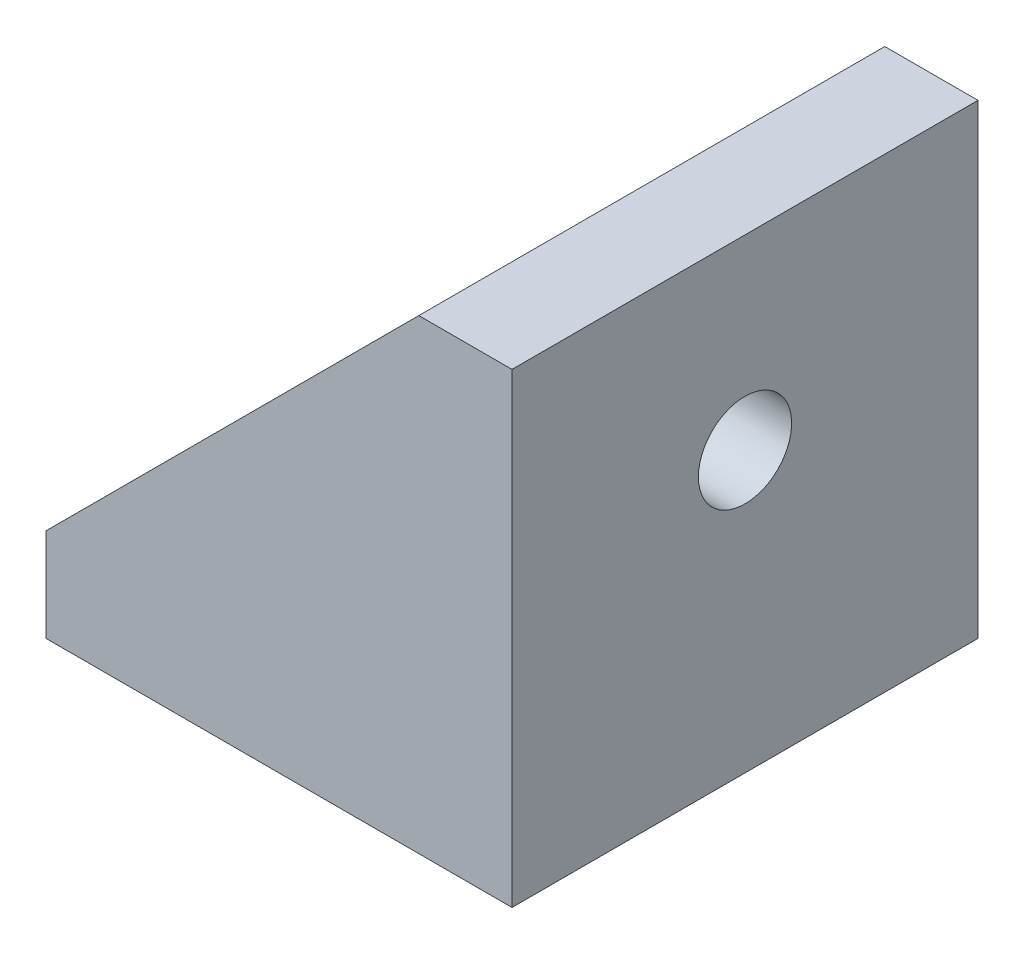
from build123d import *

# Parameters (mm, degrees)
BOSS_EXTRUDE1_DEPTH = 20
BOSS_EXTRUDE2_DEPTH = 4
BOSS_EXTRUDE3_DEPTH = 4
SKETCH4_R           = 2
CUT_EXTRUDE1_DEPTH  = 4
SKETCH5_R           = 2
CUT_EXTRUDE2_DEPTH  = 4


with BuildPart() as part:
    # Sketch1 → Boss-Extrude1 (new body)
    with BuildSketch(Plane.XY):
        Polygon((0, 0), (-20, 0), (-20, 4), (-4, 4), (-4, 20), (0, 20), align=None)
    extrude(amount=BOSS_EXTRUDE1_DEPTH)

    # Sketch2 → Boss-Extrude2 (add)
    with BuildSketch(Plane(origin=(0, 0, 0), x_dir=(-1, 0, 0), z_dir=(0, 0, -1))):
        Polygon((4, 20), (20, 4), (4, 4), align=None)
    extrude(amount=-BOSS_EXTRUDE2_DEPTH)

    # Sketch3 → Boss-Extrude3 (add)
    with BuildSketch(Plane.XY.offset(20)):
        Polygon((-4, 20), (-20, 4), (-4, 4), align=None)
    extrude(amount=-BOSS_EXTRUDE3_DEPTH)

    # Sketch4 → Cut-Extrude1 (cut)
    with BuildSketch(Plane(origin=(0, 4, 0), x_dir=(1, 0, 0), z_dir=(0, 1, 0))):
        with Locations((-12, -10)):
            Circle(SKETCH4_R)
    extrude(amount=-CUT_EXTRUDE1_DEPTH, mode=Mode.SUBTRACT)

    # Sketch5 → Cut-Extrude2 (cut)
    with BuildSketch(Plane.ZY.offset(4)):
        with Locations((10, 12)):
            Circle(SKETCH5_R)
    extrude(amount=-CUT_EXTRUDE2_DEPTH, mode=Mode.SUBTRACT)


solid = part.part
